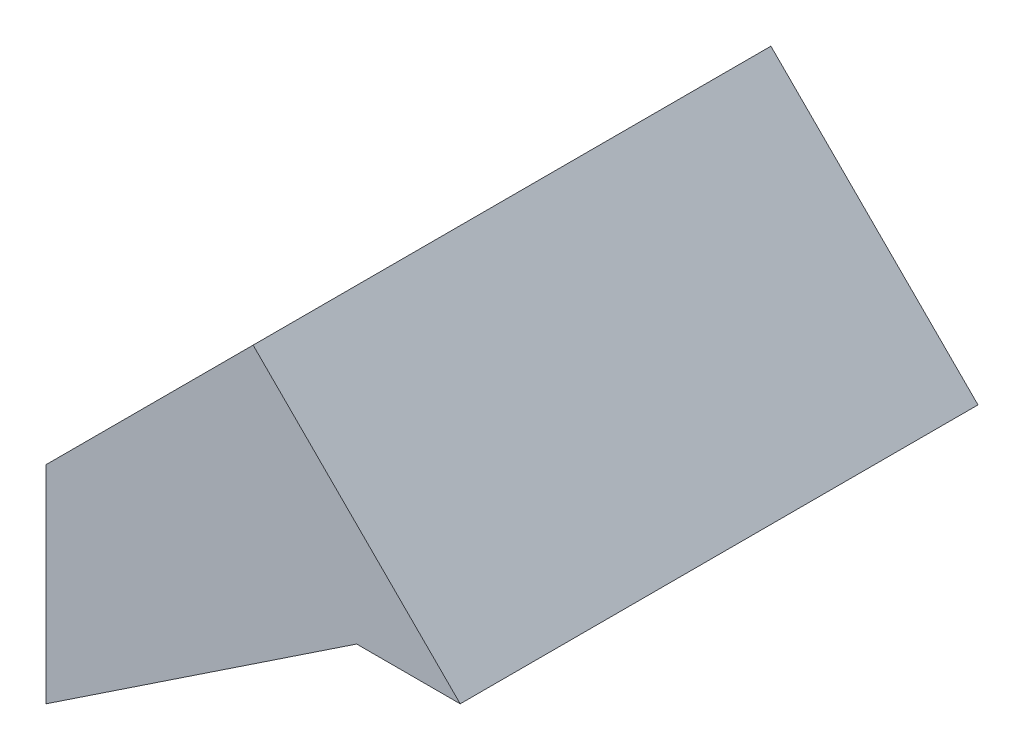
from build123d import *

# Parameters (mm, degrees)
BOSS_EXTRUDE1_DEPTH = 25


with BuildPart() as part:
    # Sketch1 → Boss-Extrude1 (new body)
    with BuildSketch(Plane.XY):
        Polygon((-20, 0), (-10, 10), (0, 0), (-5, 0), (-20, -10), align=None)
    extrude(amount=BOSS_EXTRUDE1_DEPTH)


solid = part.part
